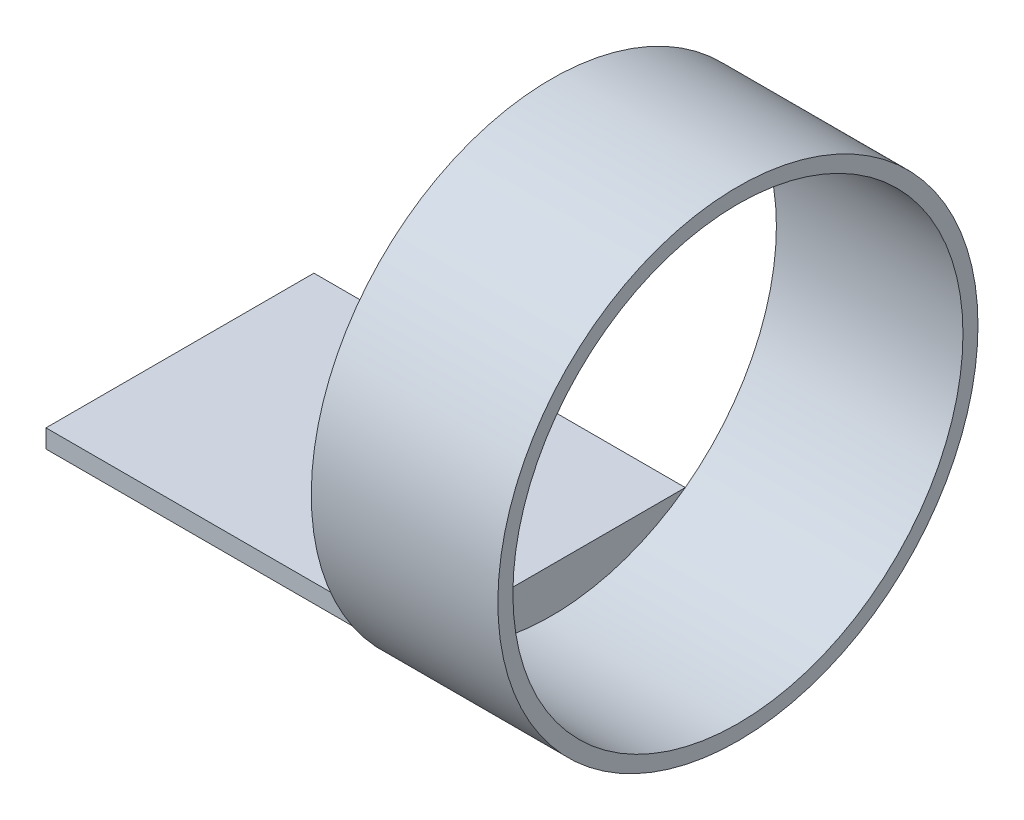
from build123d import *

# Parameters (mm, degrees)
SKETCH1_R           = 27.15
BOSS_EXTRUDE1_DEPTH = 21.1
SKETCH2_R           = 25.45
CUT_EXTRUDE1_DEPTH  = 21.1
BOSS_EXTRUDE3_DEPTH = 42


with BuildPart() as part:
    # Sketch1 → Boss-Extrude1 (new body)
    with BuildSketch(Plane(origin=(0, 0, 0), x_dir=(0, 0, -1), z_dir=(1, 0, 0))):
        Circle(SKETCH1_R)
    extrude(amount=BOSS_EXTRUDE1_DEPTH)

    # Sketch2 → Cut-Extrude1 (cut)
    with BuildSketch(Plane(origin=(21.1, 0, 0), x_dir=(0, 0, -1), z_dir=(1, 0, 0))):
        Circle(SKETCH2_R)
    extrude(amount=-CUT_EXTRUDE1_DEPTH, mode=Mode.SUBTRACT)

    # Sketch3 → Boss-Extrude3 (add)
    with BuildSketch(Plane.ZY):
        with BuildLine():
            Line((0, -20.45), (-15.149257408, -20.45))
            Line((-15.149257408, -20.45), (-15.149257408, -22.530479356))
            ThreePointArc((-15.149257408, -22.530479356), (0, -27.15), (15.149257408, -22.530479356))
            Line((15.149257408, -22.530479356), (15.149257408, -20.45))
            Line((15.149257408, -20.45), (0, -20.45))
        make_face()
    extrude(amount=BOSS_EXTRUDE3_DEPTH)


solid = part.part
